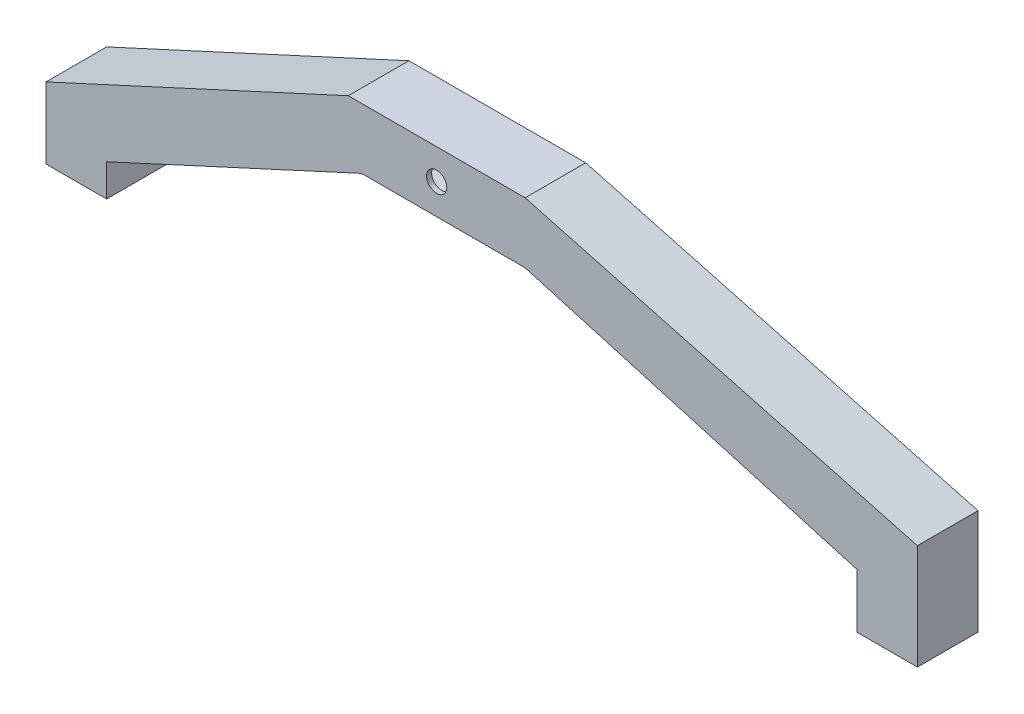
from build123d import *

# Parameters (mm, degrees)
BOSS_EXTRUDE1_DEPTH = 12
SHELL1_T            = -1
SKETCH2_W           = 10
SKETCH2_H           = 10
CUT_EXTRUDE1_DEPTH  = 12
SKETCH3_R           = 2
CUT_EXTRUDE2_DEPTH  = 12
CUT_EXTRUDE3_REACH  = 43.63
SKETCH5_W           = 0.21800788
SKETCH5_H           = 12


with BuildPart() as part:
    # Sketch1 → Boss-Extrude1 (new body)
    with BuildSketch(Plane.XY):
        Polygon((82.939086493, -35.63), (82.939086493, -24.776717085), (17.5, -6), (-14.870410096, -6), (-65.342905627, -29.23610302), (-65.342905627, -35.63), (-77.342905627, -35.63), (-77.342905627, -21.549973615), (-17.5, 6), (17.5, 6), (95.157094373, -14.812940234), (95.157094373, -35.63), align=None)
    extrude(amount=BOSS_EXTRUDE1_DEPTH)

    # Shell1
    shell1_openings = [part.faces().sort_by_distance(p)[0] for p in [
        (-71.342905627, -35.63, 6),
    ]]
    offset(amount=SHELL1_T, openings=shell1_openings, kind=Kind.INTERSECTION)

    # Sketch2 → Cut-Extrude1 (cut)
    with BuildSketch(Plane.XZ.offset(35.63)):
        with Locations((89.157094373, 6.101364163)):
            Rectangle(SKETCH2_W, SKETCH2_H)
    extrude(amount=-CUT_EXTRUDE1_DEPTH, mode=Mode.SUBTRACT)

    # Sketch3 → Cut-Extrude2 (cut)
    with BuildSketch(Plane.XY.offset(12)):
        Circle(SKETCH3_R)
    extrude(amount=-CUT_EXTRUDE2_DEPTH, mode=Mode.SUBTRACT)

    # Cut-Extrude3: up to this face of the body (flat: up to its plane)
    cut_extrude3_end = Plane(part.part.faces().sort_by_distance((50.219543247, -15.388358542, 6))[0])
    # Sketch5 → Cut-Extrude3 (cut, up to the picked face)
    with BuildSketch(Plane.XZ.offset(35.63), mode=Mode.PRIVATE) as cut_extrude3_sk1:
        with Locations((83.048090433, 6)):
            Rectangle(SKETCH5_W, SKETCH5_H)
    cut_extrude3_tool1 = split(extrude(cut_extrude3_sk1.sketch, amount=-CUT_EXTRUDE3_REACH, mode=Mode.PRIVATE), bisect_by=cut_extrude3_end, keep=Keep.BOTH, mode=Mode.PRIVATE)
    add(cut_extrude3_tool1.solids().sort_by_distance((83.04809, -35.63, 6))[0], mode=Mode.SUBTRACT)


solid = part.part
